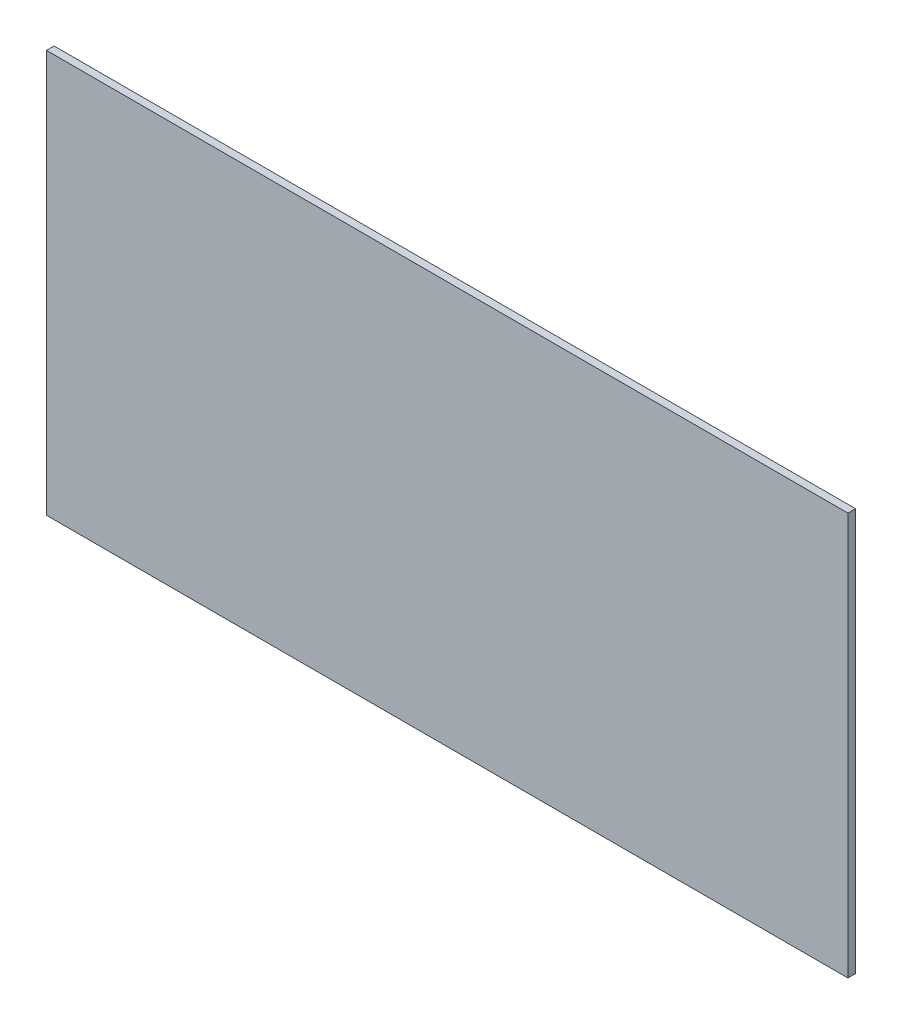
from build123d import *

# Parameters (mm, degrees)
SKETCH1_W           = 13.3985
SKETCH1_H           = 6.731
BOSS_EXTRUDE1_DEPTH = 0.127


with BuildPart() as part:
    # Sketch1 → Boss-Extrude1 (new body)
    with BuildSketch(Plane.XY):
        with Locations((23.121102666, 199.184077882)):
            Rectangle(SKETCH1_W, SKETCH1_H)
    extrude(amount=BOSS_EXTRUDE1_DEPTH)


solid = part.part
